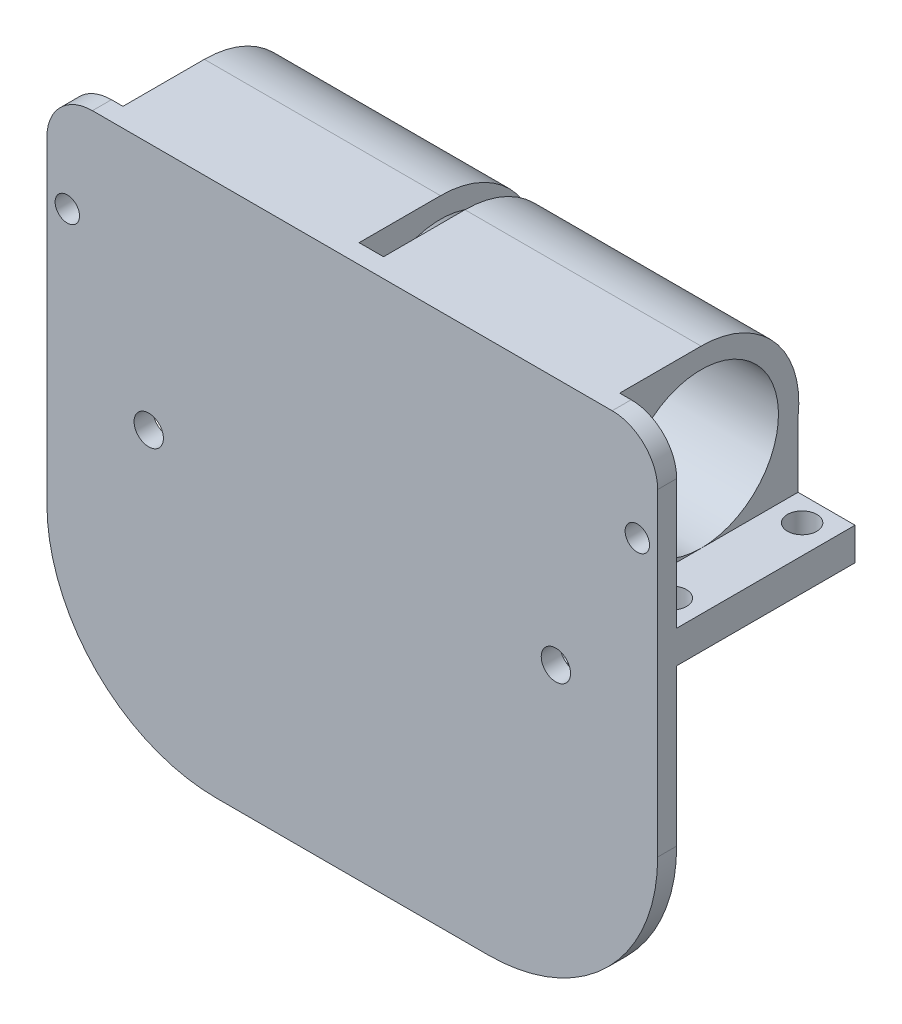
from build123d import *

# Parameters (mm, degrees)
SKETCH1_R            = 1.79994
SKETCH1_R_2          = 1.5
BOSS_EXTRUDE1_DEPTH  = 7
SKETCH2_W            = 75
SKETCH2_H            = 13.099999962
SKETCH2_R            = 2.6999438
SKETCH2_R_2          = 2.499995
SKETCH2_R_3          = 1.3498449
BOSS_EXTRUDE2_DEPTH  = 6.987999994
SKETCH2_3_R          = 2.6999438
SKETCH2_3_R_2        = 1.3498449
CUT_EXTRUDE1_DEPTH   = 2.5
SKETCH5_W            = 75
SKETCH5_H            = 13.099999962
CUT_EXTRUDE3_DEPTH   = 21.082
SKETCH6_W            = 75
SKETCH6_H            = 7
BOSS_EXTRUDE3_DEPTH  = 9.5
SKETCH8_W            = 75
SKETCH8_H            = 38.030205227
CUT_EXTRUDE4_DEPTH   = 4.666
SKETCH10_W           = 75
SKETCH10_H           = 2.334
BOSS_EXTRUDE5_DEPTH  = 35
SKETCH11_R           = 1.79994
CUT_EXTRUDE5_DEPTH   = 5
SKETCH15_W           = 44.653530321
SKETCH15_H           = 13.617301916
SKETCH15_W_2         = 11.728266088
SKETCH15_H_2         = 5.987537529
BOSS_EXTRUDE7_DEPTH  = 2.334
SKETCH16_R           = 9.5
BOSS_EXTRUDE9_DEPTH  = 29
SKETCH17_R           = 9.5
BOSS_EXTRUDE11_DEPTH = 14.5
FILLET5_R            = 20.828
FILLET6_R            = 5.588
BOSS_EXTRUDE13_DEPTH = 21.905881
CUT_EXTRUDE6_REACH   = 46
SKETCH21_R           = 1.8


with BuildPart() as part:
    # Sketch1 → Boss-Extrude1 (new body)
    with BuildSketch(Plane.XY):
        with BuildLine():
            Line((37.5, -10.5), (30, -10.5))
            ThreePointArc((30, -10.5), (25, -15.5), (20, -10.5))
            Line((20, -10.5), (5, -10.5))
            ThreePointArc((5, -10.5), (0, -15.5), (-5, -10.5))
            Line((-5, -10.5), (-20, -10.5))
            ThreePointArc((-20, -10.5), (-25, -15.5), (-30, -10.5))
            Line((-30, -10.5), (-37.5, -10.5))
            Line((-37.5, -10.5), (-37.5, 10.5))
            Line((-37.5, 10.5), (37.5, 10.5))
            Line((37.5, 10.5), (37.5, -10.5))
        make_face()
        with Locations((-25, -10.5)):
            Circle(SKETCH1_R, mode=Mode.SUBTRACT)
        with Locations((0, -10.5)):
            Circle(SKETCH1_R, mode=Mode.SUBTRACT)
        with Locations((25, -10.5)):
            Circle(SKETCH1_R, mode=Mode.SUBTRACT)
        with Locations((-35, 8)):
            Circle(SKETCH1_R_2, mode=Mode.SUBTRACT)
        with Locations((-15, 8)):
            Circle(SKETCH1_R_2, mode=Mode.SUBTRACT)
        with Locations((-10, 8)):
            Circle(SKETCH1_R_2, mode=Mode.SUBTRACT)
        with Locations((10, 8)):
            Circle(SKETCH1_R_2, mode=Mode.SUBTRACT)
        with Locations((35, 8)):
            Circle(SKETCH1_R_2, mode=Mode.SUBTRACT)
        with Locations((15, 8)):
            Circle(SKETCH1_R_2, mode=Mode.SUBTRACT)
    extrude(amount=BOSS_EXTRUDE1_DEPTH)

    # Sketch2 → Boss-Extrude2 (add)
    with BuildSketch(Plane(origin=(0, 2.24999999, 0), x_dir=(1, 0, 0), z_dir=(0, 1, 0))):
        with Locations((0, -13.549999981)):
            Rectangle(SKETCH2_W, SKETCH2_H)
        with Locations((31.0001404, -13.549999981)):
            Circle(SKETCH2_R, mode=Mode.SUBTRACT)
        with Locations((-31.0001404, -13.549999981)):
            Circle(SKETCH2_R, mode=Mode.SUBTRACT)
        with Locations((-25, -13.549999981)):
            Circle(SKETCH2_R_2, mode=Mode.SUBTRACT)
        with Locations((-6.0001404, -13.549999981)):
            Circle(SKETCH2_R, mode=Mode.SUBTRACT)
        with Locations((6.0001404, -13.549999981)):
            Circle(SKETCH2_R, mode=Mode.SUBTRACT)
        with Locations((0, -13.549999981)):
            Circle(SKETCH2_R_2, mode=Mode.SUBTRACT)
        with Locations((-18.9998596, -13.549999981)):
            Circle(SKETCH2_R, mode=Mode.SUBTRACT)
        with Locations((25, -13.549999981)):
            Circle(SKETCH2_R_2, mode=Mode.SUBTRACT)
        with Locations((18.9998596, -13.549999981)):
            Circle(SKETCH2_R, mode=Mode.SUBTRACT)
        with Locations((-31.0001404, -13.549999981)):
            Circle(SKETCH2_R)
        with Locations((-31.0001404, -13.549999981)):
            Circle(SKETCH2_R_3, mode=Mode.SUBTRACT)
        with Locations((-18.9998596, -13.549999981)):
            Circle(SKETCH2_R)
        with Locations((-18.9998596, -13.549999981)):
            Circle(SKETCH2_R_3, mode=Mode.SUBTRACT)
        with Locations((-6.0001404, -13.549999981)):
            Circle(SKETCH2_R)
        with Locations((-6.0001404, -13.549999981)):
            Circle(SKETCH2_R_3, mode=Mode.SUBTRACT)
        with Locations((6.0001404, -13.549999981)):
            Circle(SKETCH2_R)
        with Locations((6.0001404, -13.549999981)):
            Circle(SKETCH2_R_3, mode=Mode.SUBTRACT)
        with Locations((18.9998596, -13.549999981)):
            Circle(SKETCH2_R)
        with Locations((18.9998596, -13.549999981)):
            Circle(SKETCH2_R_3, mode=Mode.SUBTRACT)
        with Locations((31.0001404, -13.549999981)):
            Circle(SKETCH2_R)
        with Locations((31.0001404, -13.549999981)):
            Circle(SKETCH2_R_3, mode=Mode.SUBTRACT)
    extrude(amount=-BOSS_EXTRUDE2_DEPTH)

    # Sketch2_3 → Cut-Extrude1 (cut)
    with BuildSketch(Plane(origin=(0, 2.24999999, 0), x_dir=(1, 0, 0), z_dir=(0, 1, 0))):
        with Locations((-31.0001404, -13.549999981)):
            Circle(SKETCH2_3_R)
        with Locations((-31.0001404, -13.549999981)):
            Circle(SKETCH2_3_R_2, mode=Mode.SUBTRACT)
        with Locations((-18.9998596, -13.549999981)):
            Circle(SKETCH2_3_R)
        with Locations((-18.9998596, -13.549999981)):
            Circle(SKETCH2_3_R_2, mode=Mode.SUBTRACT)
        with Locations((-6.0001404, -13.549999981)):
            Circle(SKETCH2_3_R)
        with Locations((-6.0001404, -13.549999981)):
            Circle(SKETCH2_3_R_2, mode=Mode.SUBTRACT)
        with Locations((6.0001404, -13.549999981)):
            Circle(SKETCH2_3_R)
        with Locations((6.0001404, -13.549999981)):
            Circle(SKETCH2_3_R_2, mode=Mode.SUBTRACT)
        with Locations((18.9998596, -13.549999981)):
            Circle(SKETCH2_3_R)
        with Locations((18.9998596, -13.549999981)):
            Circle(SKETCH2_3_R_2, mode=Mode.SUBTRACT)
        with Locations((31.0001404, -13.549999981)):
            Circle(SKETCH2_3_R)
        with Locations((31.0001404, -13.549999981)):
            Circle(SKETCH2_3_R_2, mode=Mode.SUBTRACT)
    extrude(amount=-CUT_EXTRUDE1_DEPTH, mode=Mode.SUBTRACT)

    # Sketch5 → Cut-Extrude3 (cut)
    with BuildSketch(Plane(origin=(0, 2.24999999, 0), x_dir=(1, 0, 0), z_dir=(0, 1, 0))):
        with Locations((0, -13.549999981)):
            Rectangle(SKETCH5_W, SKETCH5_H)
    extrude(amount=-CUT_EXTRUDE3_DEPTH, mode=Mode.SUBTRACT)

    # Sketch6 → Boss-Extrude3 (add)
    with BuildSketch(Plane(origin=(0, 10.5, 0), x_dir=(1, 0, 0), z_dir=(0, 1, 0))):
        with Locations((0, -3.5)):
            Rectangle(SKETCH6_W, SKETCH6_H)
    extrude(amount=BOSS_EXTRUDE3_DEPTH)

    # Sketch8 → Cut-Extrude4 (cut)
    with BuildSketch(Plane(origin=(0, 0, 0), x_dir=(-1, 0, 0), z_dir=(0, 0, -1))):
        with Locations((0, 0.984897387)):
            Rectangle(SKETCH8_W, SKETCH8_H)
    extrude(amount=-CUT_EXTRUDE4_DEPTH, mode=Mode.SUBTRACT)

    # Sketch10 → Boss-Extrude5 (add)
    with BuildSketch(Plane(origin=(0, -45.5, 0), x_dir=(-1, 0, 0), z_dir=(0, -1, 0))):
        with Locations((0, -5.833)):
            Rectangle(SKETCH10_W, SKETCH10_H)
    extrude(amount=-BOSS_EXTRUDE5_DEPTH)

    # Sketch11 → Cut-Extrude5 (cut)
    with BuildSketch(Plane(origin=(0, 0, 4.666), x_dir=(-1, 0, 0), z_dir=(0, 0, -1))):
        with Locations((-25, -10.5)):
            Circle(SKETCH11_R)
        with Locations((0, -10.5)):
            Circle(SKETCH11_R)
        with Locations((25, -10.5)):
            Circle(SKETCH11_R)
    extrude(amount=-CUT_EXTRUDE5_DEPTH, mode=Mode.SUBTRACT)

    # Sketch15 → Boss-Extrude7 (add)
    with BuildSketch(Plane.XY.offset(7)):
        with Locations((1.804442165, 8.803924913)):
            Rectangle(SKETCH15_W, SKETCH15_H)
        with Locations((-1.501191344, -11.287680254)):
            Rectangle(SKETCH15_W_2, SKETCH15_H_2)
    extrude(amount=-BOSS_EXTRUDE7_DEPTH)


with BuildPart() as body_2:
    # Sketch16 → Boss-Extrude9 (new body)
    with BuildSketch(Plane(origin=(30.50000003, 0, 0), x_dir=(0, 0, -1), z_dir=(1, 0, 0))):
        with BuildLine():
            Line((-4.666, -4), (5.334, -4))
            Line((5.334, -4), (17.2398809, -4))
            Line((17.2398809, -4), (17.2398809, 6.5))
            ThreePointArc((17.2398809, 6.5), (14.334, 15.937253933), (5.334, 20))
            Line((5.334, 20), (-4.666, 20))
            Line((-4.666, 20), (-4.666, -4))
        make_face()
        with Locations((5.334, 8)):
            Circle(SKETCH16_R, mode=Mode.SUBTRACT)
    extrude(amount=-BOSS_EXTRUDE9_DEPTH)


with BuildPart() as body_3:
    # Mirror1: mirrored copy
    add(body_2.part.mirror(Plane(origin=(0, 0, 0), x_dir=(0, 0, 1), z_dir=(1, 0, 0))))

    # Combine1: union body 2, part
    add(body_2.part)
    add(part.part)

    # Sketch17 → Boss-Extrude11 (add, symmetric)
    with BuildSketch(Plane(origin=(0, 0, 0), x_dir=(0, 0, -1), z_dir=(1, 0, 0))):
        with BuildLine():
            Line((5.334, -45.5), (-4.666, -45.5))
            Line((-4.666, -45.5), (-4.666, -21.5))
            Line((-4.666, -21.5), (5.334, -21.5))
            ThreePointArc((5.334, -21.5), (17.334, -33.5), (5.334, -45.5))
        make_face()
        with Locations((5.334, -33.5)):
            Circle(SKETCH17_R, mode=Mode.SUBTRACT)
    extrude(amount=BOSS_EXTRUDE11_DEPTH, both=True)

    # Fillet5
    fillet5_edges = [body_3.edges().sort_by_distance(p)[0] for p in [
        (37.5, -45.5, 5.833),
        (-37.5, -45.5, 5.833),
    ]]
    fillet(fillet5_edges, radius=FILLET5_R)

    # Fillet6
    fillet6_edges = [body_3.edges().sort_by_distance(p)[0] for p in [
        (-37.5, 20, 5.833),
        (37.5, 20, 5.833),
    ]]
    fillet(fillet6_edges, radius=FILLET6_R)

    # Sketch20 → Boss-Extrude13 (add)
    with BuildSketch(Plane(origin=(0, 0, 4.666), x_dir=(-1, 0, 0), z_dir=(0, 0, -1))):
        with BuildLine():
            Line((-37.5, -1.5), (37.5, -1.5))
            Line((37.5, -1.5), (37.5, -5.5))
            ThreePointArc((37.5, -5.5), (0, -7.5), (-37.5, -5.5))
            Line((-37.5, -5.5), (-37.5, -1.5))
        make_face()
    extrude(amount=BOSS_EXTRUDE13_DEPTH)

    # Sketch21 → Cut-Extrude6 (cut, up to next)
    with BuildSketch(Plane(origin=(0, -1.5, 0), x_dir=(1, 0, 0), z_dir=(0, 1, 0)), mode=Mode.PRIVATE) as cut_extrude6_sk1:
        with Locations((34, 14.2398809)):
            Circle(SKETCH21_R)
    cut_extrude6_tool1 = extrude(cut_extrude6_sk1.sketch, amount=-CUT_EXTRUDE6_REACH, mode=Mode.PRIVATE) & body_3.part
    add(cut_extrude6_tool1.solids().sort_by_distance((34, -1.5, -14.239881))[0], mode=Mode.SUBTRACT)
    # Sketch21 → Cut-Extrude6 (cut, up to next)
    with BuildSketch(Plane(origin=(0, -1.5, 0), x_dir=(1, 0, 0), z_dir=(0, 1, 0)), mode=Mode.PRIVATE) as cut_extrude6_sk2:
        with Locations((34, -1.7601191)):
            Circle(SKETCH21_R)
    cut_extrude6_tool2 = extrude(cut_extrude6_sk2.sketch, amount=-CUT_EXTRUDE6_REACH, mode=Mode.PRIVATE) & body_3.part
    add(cut_extrude6_tool2.solids().sort_by_distance((34, -1.5, 1.760119))[0], mode=Mode.SUBTRACT)
    # Sketch21 → Cut-Extrude6 (cut, up to next)
    with BuildSketch(Plane(origin=(0, -1.5, 0), x_dir=(1, 0, 0), z_dir=(0, 1, 0)), mode=Mode.PRIVATE) as cut_extrude6_sk3:
        with Locations((-34, -1.7601191)):
            Circle(SKETCH21_R)
    cut_extrude6_tool3 = extrude(cut_extrude6_sk3.sketch, amount=-CUT_EXTRUDE6_REACH, mode=Mode.PRIVATE) & body_3.part
    add(cut_extrude6_tool3.solids().sort_by_distance((-34, -1.5, 1.760119))[0], mode=Mode.SUBTRACT)
    # Sketch21 → Cut-Extrude6 (cut, up to next)
    with BuildSketch(Plane(origin=(0, -1.5, 0), x_dir=(1, 0, 0), z_dir=(0, 1, 0)), mode=Mode.PRIVATE) as cut_extrude6_sk4:
        with Locations((-34, 14.2398809)):
            Circle(SKETCH21_R)
    cut_extrude6_tool4 = extrude(cut_extrude6_sk4.sketch, amount=-CUT_EXTRUDE6_REACH, mode=Mode.PRIVATE) & body_3.part
    add(cut_extrude6_tool4.solids().sort_by_distance((-34, -1.5, -14.239881))[0], mode=Mode.SUBTRACT)


solid = body_3.part
